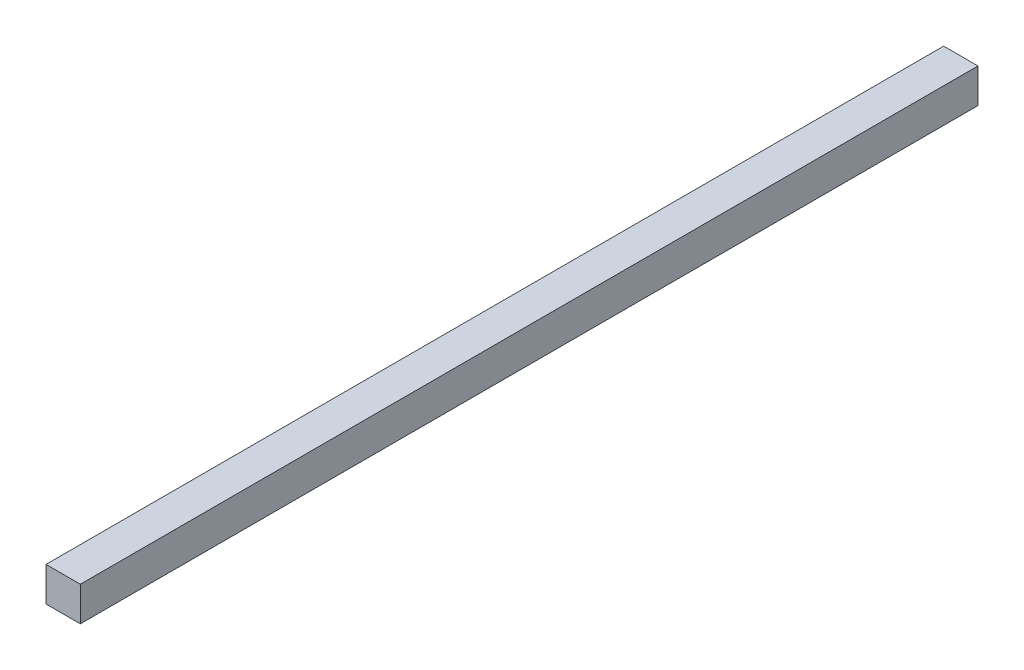
from build123d import *

# Parameters (mm, degrees)
SKETCH1_W           = 20
SKETCH1_H           = 20
BOSS_EXTRUDE1_DEPTH = 523


with BuildPart() as part:
    # Sketch1 → Boss-Extrude1 (new body)
    with BuildSketch(Plane.XY):
        Rectangle(SKETCH1_W, SKETCH1_H)
    extrude(amount=BOSS_EXTRUDE1_DEPTH)


solid = part.part
